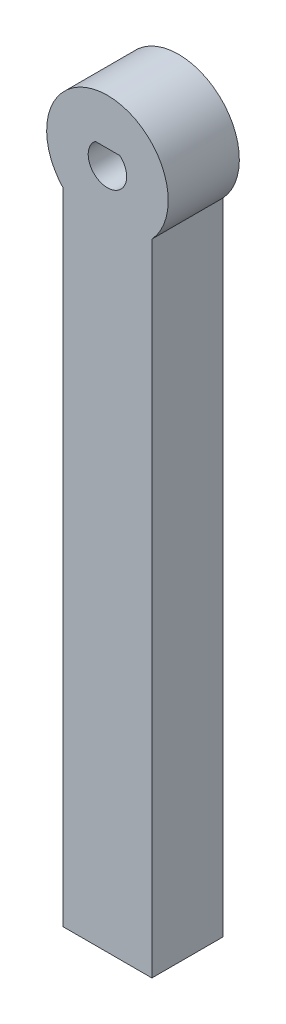
from build123d import *

# Parameters (mm, degrees)
SKETCH1_R           = 10.259142264
SKETCH1_W           = 15
SKETCH1_H           = 108
BOSS_EXTRUDE1_DEPTH = 12
SKETCH2_R           = 3.25
CUT_EXTRUDE1_DEPTH  = 9
BOSS_EXTRUDE2_DEPTH = 9


with BuildPart() as part:
    # Sketch1 → Boss-Extrude1 (new body)
    with BuildSketch(Plane.XY):
        with Locations((-20.413846154, 65.486153846)):
            Circle(SKETCH1_R)
        with Locations((-20.413846154, 4.486153846)):
            Rectangle(SKETCH1_W, SKETCH1_H)
    extrude(amount=BOSS_EXTRUDE1_DEPTH)

    # Sketch2 → Cut-Extrude1 (cut)
    with BuildSketch(Plane.XY.offset(12)):
        with Locations((-20.413846154, 65.486153846)):
            Circle(SKETCH2_R)
    extrude(amount=-CUT_EXTRUDE1_DEPTH, mode=Mode.SUBTRACT)

    # Sketch3 → Boss-Extrude2 (add)
    with BuildSketch(Plane.XY.offset(12)):
        with BuildLine():
            Line((-22.49050212, 67.986153846), (-18.337190188, 67.986153846))
            ThreePointArc((-18.337190188, 67.986153846), (-20.413846154, 68.736153846), (-22.49050212, 67.986153846))
        make_face()
    extrude(amount=-BOSS_EXTRUDE2_DEPTH)


solid = part.part
